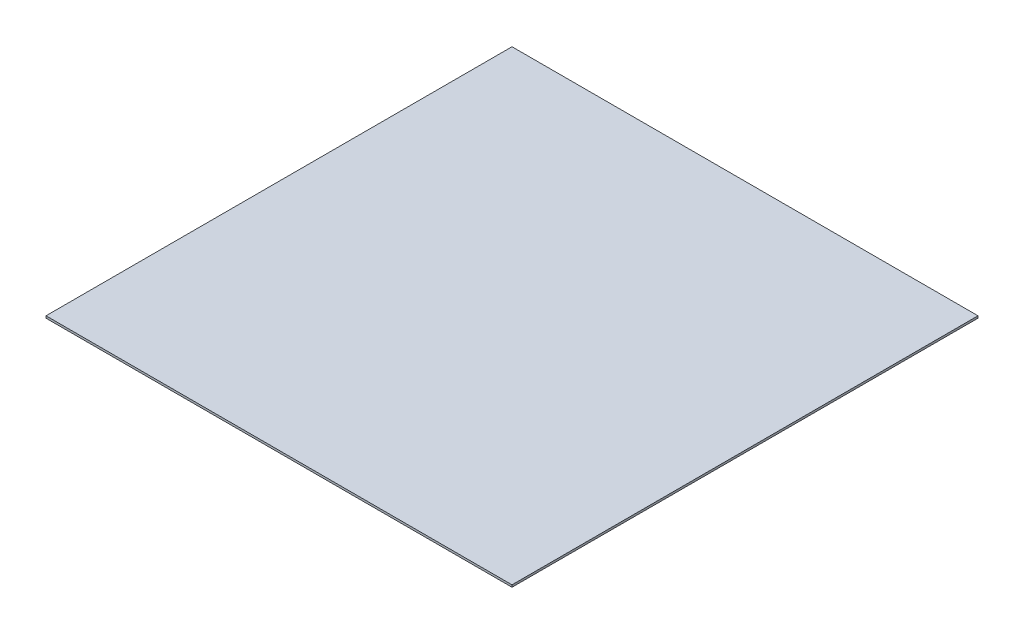
from build123d import *

# Parameters (mm, degrees)
SKETCH1_W           = 1219.2
SKETCH1_H           = 1219.2
BOSS_EXTRUDE1_DEPTH = 5.55625


with BuildPart() as part:
    # Sketch1 → Boss-Extrude1 (new body)
    with BuildSketch(Plane(origin=(0, 0, 0), x_dir=(1, 0, 0), z_dir=(0, 1, 0))):
        Rectangle(SKETCH1_W, SKETCH1_H)
    extrude(amount=BOSS_EXTRUDE1_DEPTH)


solid = part.part
